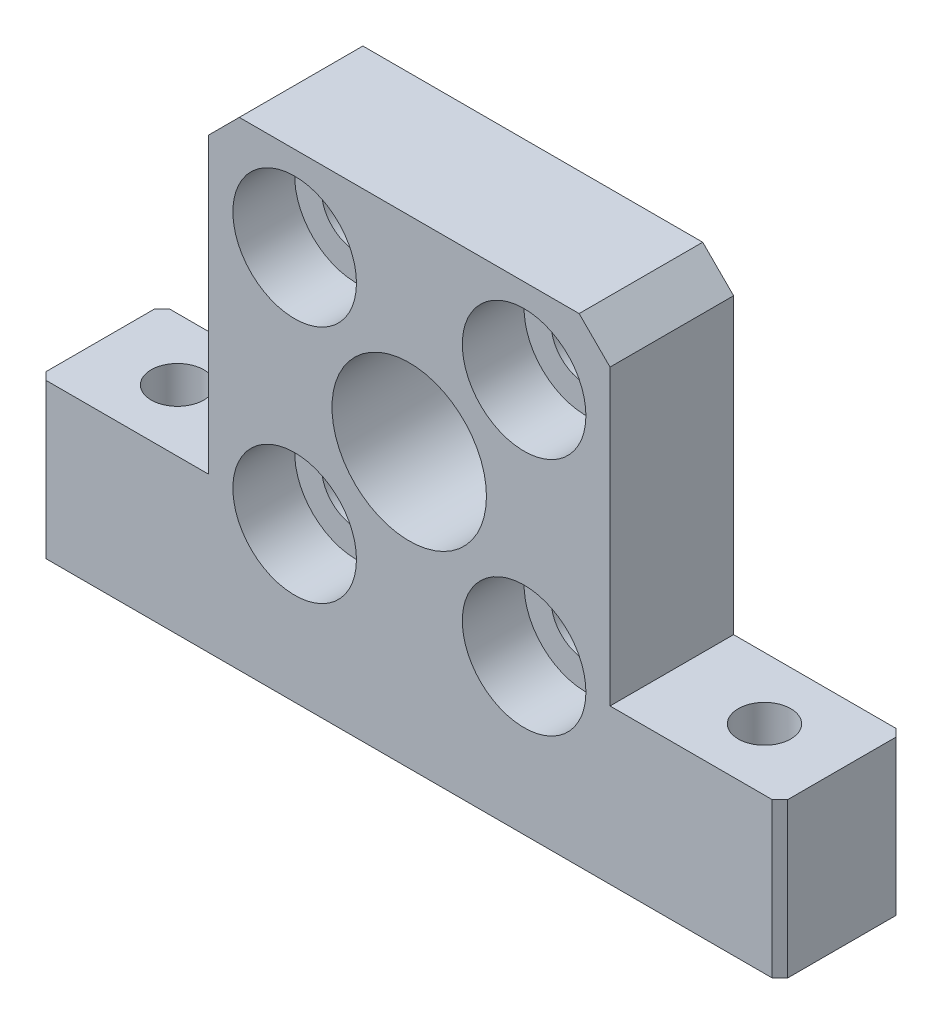
from build123d import *

# Parameters (mm, degrees)
SKETCH1_R           = 2.25
SKETCH1_R_2         = 5
BOSS_EXTRUDE1_DEPTH = 8
SKETCH2_R           = 4
CUT_EXTRUDE1_DEPTH  = 4
SKETCH3_R           = 1.701572747
CUT_EXTRUDE2_DEPTH  = 32
CHAMFER1_SIZE       = 2
CHAMFER2_SIZE       = 0.5


with BuildPart() as part:
    # Sketch1 → Boss-Extrude1 (new body)
    with BuildSketch(Plane.XY):
        Polygon((16.978142077, -11.01947541), (27.978142077, -11.01947541), (27.978142077, -21.01947541), (-20.021857923, -21.01947541), (-20.021857923, -11.01947541), (-9.021857923, -11.01947541), (-9.021857923, 9.98052459), (16.978142077, 9.98052459), align=None)
        with Locations((-3.437114754, -11.01947541)):
            Circle(SKETCH1_R, mode=Mode.SUBTRACT)
        with Locations((11.416131148, -11.01947541)):
            Circle(SKETCH1_R, mode=Mode.SUBTRACT)
        with Locations((-3.437114754, 4.48052459)):
            Circle(SKETCH1_R, mode=Mode.SUBTRACT)
        with Locations((11.416131148, 4.48052459)):
            Circle(SKETCH1_R, mode=Mode.SUBTRACT)
        with Locations((3.978142077, -3.26947541)):
            Circle(SKETCH1_R_2, mode=Mode.SUBTRACT)
    extrude(amount=BOSS_EXTRUDE1_DEPTH)

    # Sketch2 → Cut-Extrude1 (cut)
    with BuildSketch(Plane.XY.offset(8)):
        with Locations((-3.437114754, 4.48052459)):
            Circle(SKETCH2_R)
        with Locations((11.416131148, 4.48052459)):
            Circle(SKETCH2_R)
        with Locations((-3.437114754, -11.01947541)):
            Circle(SKETCH2_R)
        with Locations((11.416131148, -11.01947541)):
            Circle(SKETCH2_R)
    extrude(amount=-CUT_EXTRUDE1_DEPTH, mode=Mode.SUBTRACT)

    # Sketch3 → Cut-Extrude2 (cut, through all)
    with BuildSketch(Plane(origin=(0, 9.98052459, 0), x_dir=(1, 0, 0), z_dir=(0, 1, 0))):
        with Locations((-15.021857923, -4)):
            Circle(SKETCH3_R)
        with Locations((22.978142077, -4)):
            Circle(SKETCH3_R)
    extrude(amount=-CUT_EXTRUDE2_DEPTH, mode=Mode.SUBTRACT)

    # Chamfer1
    chamfer1_edges = [part.edges().sort_by_distance(p)[0] for p in [
        (-9.021857923, 9.98052459, 4),
        (16.978142077, 9.98052459, 4),
    ]]
    chamfer(chamfer1_edges, length=CHAMFER1_SIZE)

    # Chamfer2
    chamfer2_edges = [part.edges().sort_by_distance(p)[0] for p in [
        (-20.021857923, -16.01947541, 8),
        (27.978142077, -16.01947541, 8),
        (27.978142077, -16.01947541, 0),
        (-20.021857923, -16.01947541, 0),
    ]]
    chamfer(chamfer2_edges, length=CHAMFER2_SIZE)


solid = part.part
